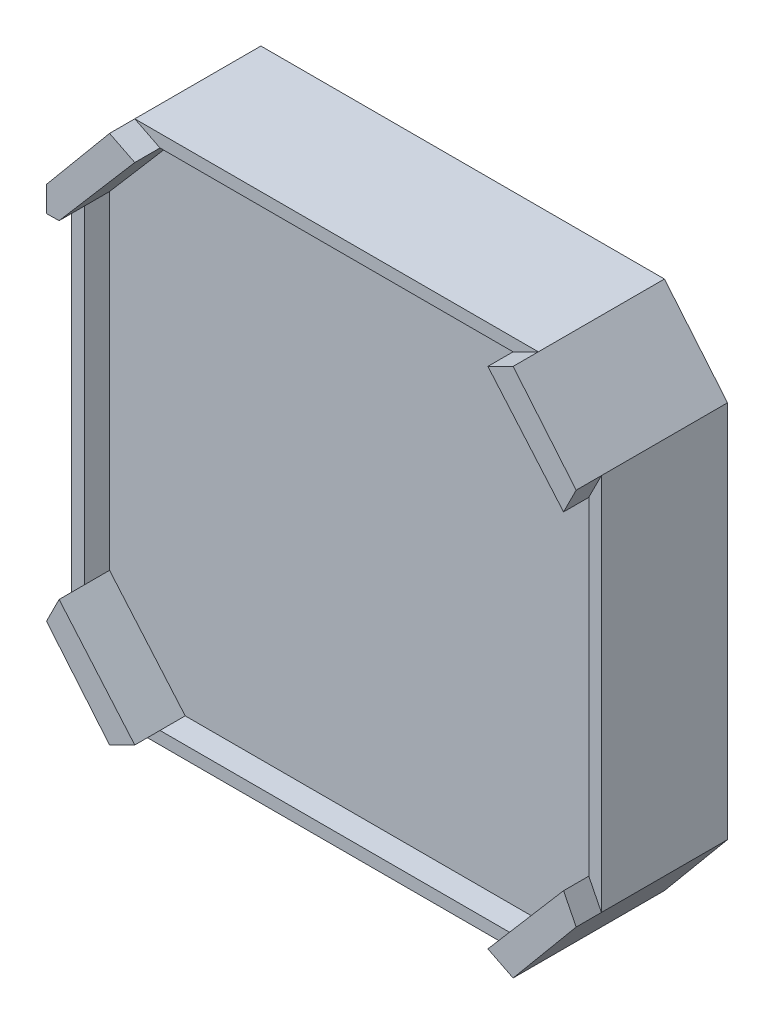
from build123d import *

# Parameters (mm, degrees)
SALIENTE_EXTRUIR1_DEPTH = 10
CORTAR_EXTRUIR1_DEPTH   = 2
SALIENTE_EXTRUIR2_DEPTH = 2
CROQUIS5_R              = 1.4
CROQUIS5_R_2            = 2.5
CORTAR_EXTRUIR2_DEPTH   = 5
CROQUIS6_R              = 15
CORTAR_EXTRUIR3_DEPTH   = 1
CROQUIS7_R              = 11
CROQUIS7_R_2            = 4
SALIENTE_EXTRUIR3_DEPTH = 3


with BuildPart() as part:
    # Croquis2 → Saliente-Extruir1 (new body)
    with BuildSketch(Plane.XY):
        Polygon((-16, 21), (16, 21), (21, 15), (21, -15), (16, -21), (-16, -21), (-21, -15), (-21, 15), align=None)
    extrude(amount=SALIENTE_EXTRUIR1_DEPTH)

    # Croquis3 → Cortar-Extruir1 (cut)
    with BuildSketch(Plane.XY.offset(10)):
        Polygon((-14, 20), (14, 20), (20, 13.004934109), (20, -13.004934109), (14, -20), (-14, -20), (-20, -13.004934109), (-20, 13.004934109), align=None)
    extrude(amount=-CORTAR_EXTRUIR1_DEPTH, mode=Mode.SUBTRACT)

    # Croquis4 → Saliente-Extruir2 (add)
    with BuildSketch(Plane.XY.offset(10)):
        Polygon((-16, -21), (-14, -20), (-20, -13.004934109), (-21, -15), align=None)
        Polygon((-20, 13.004934109), (-14, 20), (-16, 21), (-21, 15), (-21, 12.992008233), align=None)
        Polygon((16, 21), (21, 15), (20, 13.004934109), (14, 20), align=None)
        Polygon((16, -21), (21, -15), (20, -13.004934109), (14, -20), align=None)
    extrude(amount=SALIENTE_EXTRUIR2_DEPTH)

    # Croquis5 → Cortar-Extruir2 (cut)
    with BuildSketch(Plane(origin=(0, 0, 0), x_dir=(-1, 0, 0), z_dir=(0, 0, -1))):
        with Locations((15.5, 15.5)):
            Circle(CROQUIS5_R)
        with Locations((-15.5, 15.5)):
            Circle(CROQUIS5_R)
        with Locations((15.5, -15.5)):
            Circle(CROQUIS5_R)
        with Locations((-15.5, -15.5)):
            Circle(CROQUIS5_R)
        Circle(CROQUIS5_R_2)
    extrude(amount=-CORTAR_EXTRUIR2_DEPTH, mode=Mode.SUBTRACT)

    # Croquis6 → Cortar-Extruir3 (cut)
    with BuildSketch(Plane(origin=(0, 0, 0), x_dir=(-1, 0, 0), z_dir=(0, 0, -1))):
        Circle(CROQUIS6_R)
    extrude(amount=-CORTAR_EXTRUIR3_DEPTH, mode=Mode.SUBTRACT)

    # Croquis7 → Saliente-Extruir3 (add)
    with BuildSketch(Plane(origin=(0, 0, 1), x_dir=(-1, 0, 0), z_dir=(0, 0, -1))):
        Circle(CROQUIS7_R)
        Circle(CROQUIS7_R_2, mode=Mode.SUBTRACT)
    extrude(amount=SALIENTE_EXTRUIR3_DEPTH)


solid = part.part
